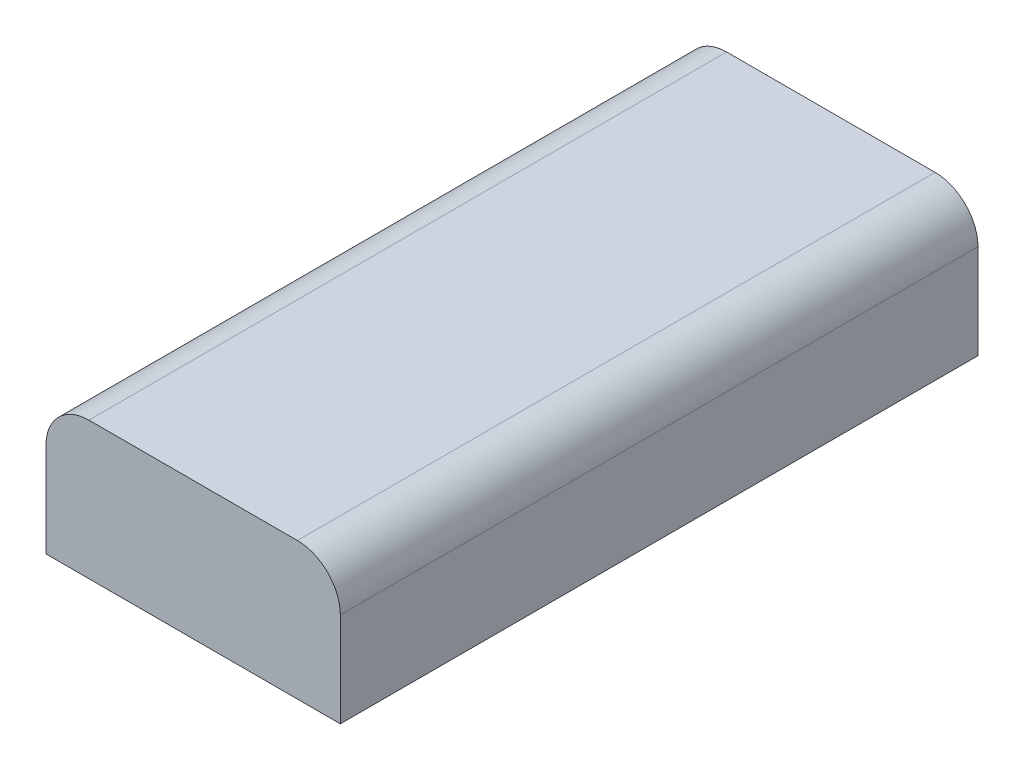
from build123d import *

# Parameters (mm, degrees)
BOSS_EXTRUDE1_DEPTH = 52


with BuildPart() as part:
    # Sketch2 → Boss-Extrude1 (new body)
    with BuildSketch(Plane.XY):
        with BuildLine():
            Line((0, 0), (24, 0))
            Line((24, 0), (24, 7.7))
            ThreePointArc((24, 7.7), (22.974873734, 10.174873734), (20.5, 11.2))
            Line((20.5, 11.2), (3.5, 11.2))
            ThreePointArc((3.5, 11.2), (1.025126266, 10.174873734), (0, 7.7))
            Line((0, 7.7), (0, 0))
        make_face()
    extrude(amount=BOSS_EXTRUDE1_DEPTH)


solid = part.part
